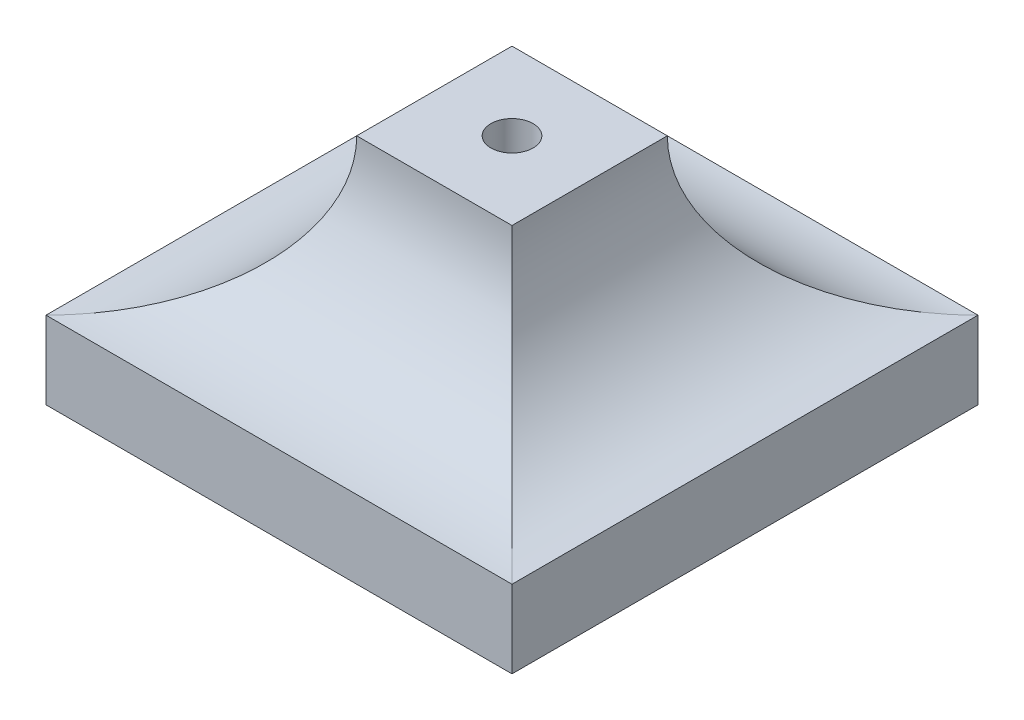
from build123d import *

# Parameters (mm, degrees)
SKETCH1_W             = 38.1
SKETCH1_H             = 38.1
BOSS_EXTRUDE1_DEPTH   = 6.35
BOSS_EXTRUDE2_DEPTH   = 38.1
CUT_EXTRUDE1_DEPTH    = 39.1
F_4_CLEARANCE_HOLE1_D = 3.4544
SKETCH6_R             = 3.96875
CUT_EXTRUDE2_DEPTH    = 6.35


with BuildPart() as part:
    # Sketch1 → Boss-Extrude1 (new body)
    with BuildSketch(Plane(origin=(0, 0, 0), x_dir=(1, 0, 0), z_dir=(0, 1, 0))):
        Rectangle(SKETCH1_W, SKETCH1_H)
    extrude(amount=BOSS_EXTRUDE1_DEPTH)

    # Sketch2 → Boss-Extrude2 (add)
    with BuildSketch(Plane.XY.offset(19.05)):
        with BuildLine():
            Line((-19.05, 6.35), (19.05, 6.35))
            ThreePointArc((19.05, 6.35), (10.069743762, 10.06974368), (6.349999801, 19.049999801))
            Line((6.349999801, 19.049999801), (-6.350000199, 19.049999801))
            ThreePointArc((-6.350000199, 19.049999801), (-10.06974402, 10.069743821), (-19.05, 6.35))
        make_face()
    extrude(amount=-BOSS_EXTRUDE2_DEPTH)

    # Sketch3 → Cut-Extrude1 (cut, through all)
    with BuildSketch(Plane(origin=(19.05, 0, 0), x_dir=(0, 0, -1), z_dir=(1, 0, 0))):
        with BuildLine():
            Line((-19.05, 6.35), (-19.05, 19.049999801))
            Line((-19.05, 19.049999801), (-6.350000199, 19.049999801))
            ThreePointArc((-6.350000199, 19.049999801), (-10.06974402, 10.069743821), (-19.05, 6.35))
        make_face()
        with BuildLine():
            Line((19.05, 6.35), (19.05, 19.049999801))
            Line((19.05, 19.049999801), (6.350000199, 19.049999801))
            ThreePointArc((6.350000199, 19.049999801), (10.06974402, 10.069743821), (19.05, 6.35))
        make_face()
    extrude(amount=-CUT_EXTRUDE1_DEPTH, mode=Mode.SUBTRACT)

    # #4 Clearance Hole1 (through all)
    with Locations(Plane(origin=(0, 19.049999801, 0), x_dir=(1, 0, 0), z_dir=(0, 1, 0))):
        with Locations((0, 0)):
            Hole(F_4_CLEARANCE_HOLE1_D / 2)

    # Sketch6 → Cut-Extrude2 (cut)
    with BuildSketch(Plane.XZ):
        Circle(SKETCH6_R)
    extrude(amount=-CUT_EXTRUDE2_DEPTH, mode=Mode.SUBTRACT)


solid = part.part
